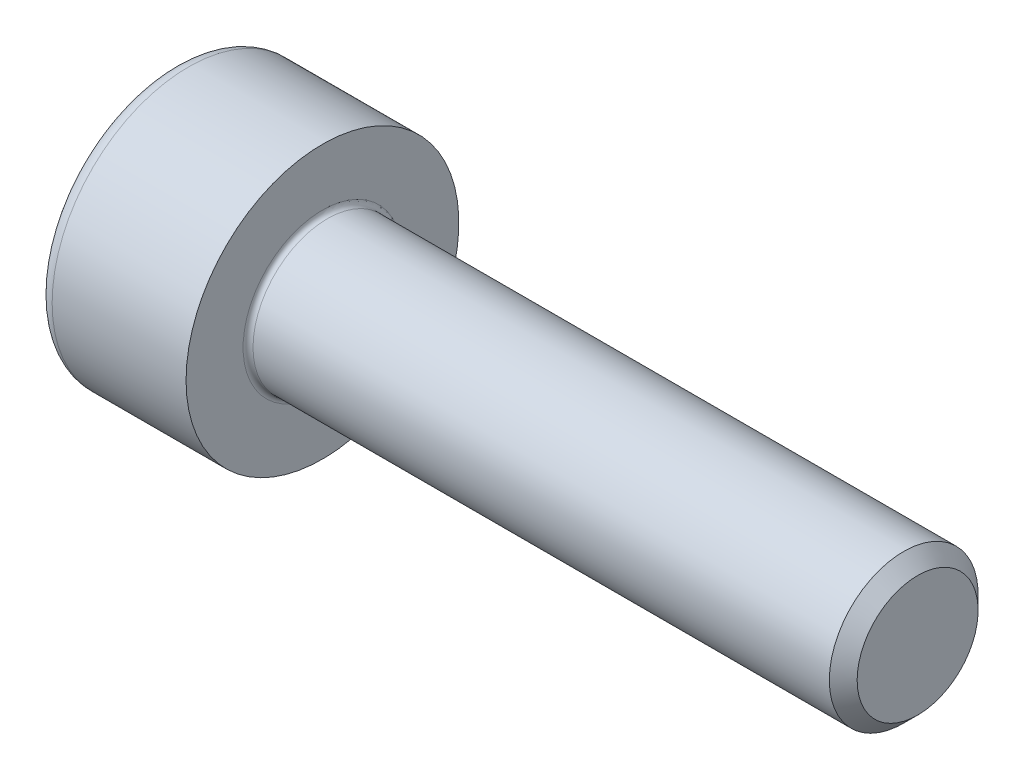
from build123d import *

# Parameters (mm, degrees)
FILLET1_R   = 0.1
FILLET2_R   = 0.3
HEX_2_DEPTH = 1.3


with BuildPart() as part:
    # BodySke → Base-Revolve (revolve)
    with BuildSketch(Plane.XY):
        Polygon((0, 0), (0, 2.75), (3, 2.75), (3, 1.5), (14.7195, 1.5), (15, 1.2195), (15, 0), align=None)
    revolve(axis=Axis((-31.75, 0, 0), (1, 0, 0)))

    # Fillet1
    fillet1_edges = [part.edges().sort_by_distance(p)[0] for p in [
        (3, -1.5, 0),
    ]]
    fillet(fillet1_edges, radius=FILLET1_R)

    # Fillet2
    fillet2_edges = [part.edges().sort_by_distance(p)[0] for p in [
        (0, -2.75, 0),
    ]]
    fillet(fillet2_edges, radius=FILLET2_R)

    # Sketch2 → Hex-PreBroach (revolve, cut)
    with BuildSketch(Plane.XY):
        Polygon((0, 1.26), (1.3, 1.26), (2.027461339, 0), (0, 0), align=None)
    revolve(axis=Axis((0, 0, 0), (1, 0, 0)), mode=Mode.SUBTRACT)

    # Sketch3 → Hex 2 (cut)
    with BuildSketch(Plane(origin=(0, 0, 0), x_dir=(0, 0.5, 0.866025404), z_dir=(-1, 0, 0))):
        Polygon((0.727461339, 1.26), (-0.727461339, 1.26), (-1.454922678, 0), (-0.727461339, -1.26), (0.727461339, -1.26), (1.454922678, 0), align=None)
    extrude(amount=-HEX_2_DEPTH, mode=Mode.SUBTRACT)


solid = part.part
